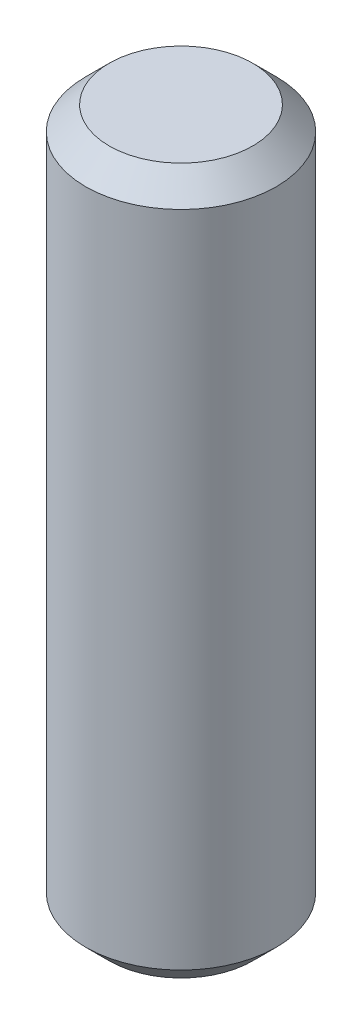
from build123d import *

# Parameters (mm, degrees)
SKETCH1_R           = 4.05
BOSS_EXTRUDE1_DEPTH = 15
CHAMFER1_SIZE       = 1


with BuildPart() as part:
    # Sketch1 → Boss-Extrude1 (new body, symmetric)
    with BuildSketch(Plane(origin=(0, 0, 0), x_dir=(1, 0, 0), z_dir=(0, 1, 0))):
        Circle(SKETCH1_R)
    extrude(amount=BOSS_EXTRUDE1_DEPTH, both=True)

    # Chamfer1
    chamfer1_edges = [part.edges().sort_by_distance(p)[0] for p in [
        (-4.05, -15, 0),
        (-4.05, 15, 0),
    ]]
    chamfer(chamfer1_edges, length=CHAMFER1_SIZE)


solid = part.part
